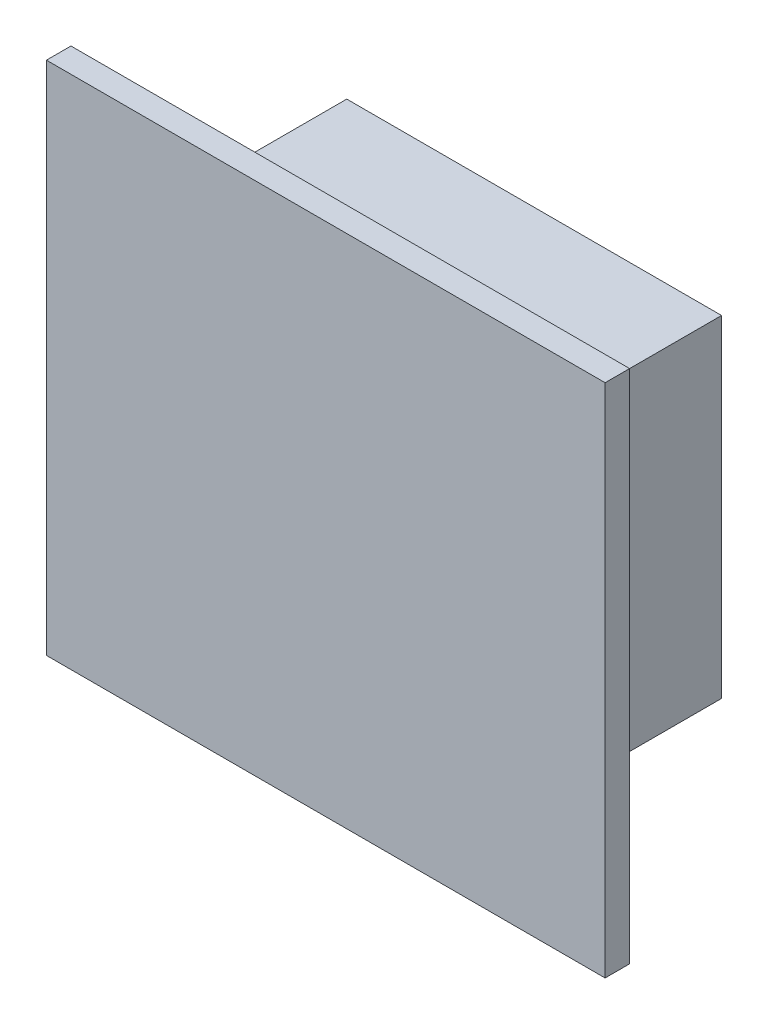
from build123d import *

# Parameters (mm, degrees)
SKETCH1_W           = 9.115192329
SKETCH1_H           = 8.411491988
BOSS_EXTRUDE1_DEPTH = 0.4
SKETCH2_W           = 6.115192329
SKETCH2_H           = 5.411491988
BOSS_EXTRUDE2_DEPTH = 3


with BuildPart() as part:
    # Sketch1 → Boss-Extrude1 (new body)
    with BuildSketch(Plane.XY):
        with Locations((43.481700364, -44.117460707)):
            Rectangle(SKETCH1_W, SKETCH1_H)
    extrude(amount=BOSS_EXTRUDE1_DEPTH)

    # Sketch2 → Boss-Extrude2 (add)
    with BuildSketch(Plane(origin=(0, 0, 0), x_dir=(-1, 0, 0), z_dir=(0, 0, -1))):
        with Locations((-43.481700364, -44.117460707)):
            Rectangle(SKETCH2_W, SKETCH2_H)
    extrude(amount=BOSS_EXTRUDE2_DEPTH)


solid = part.part
